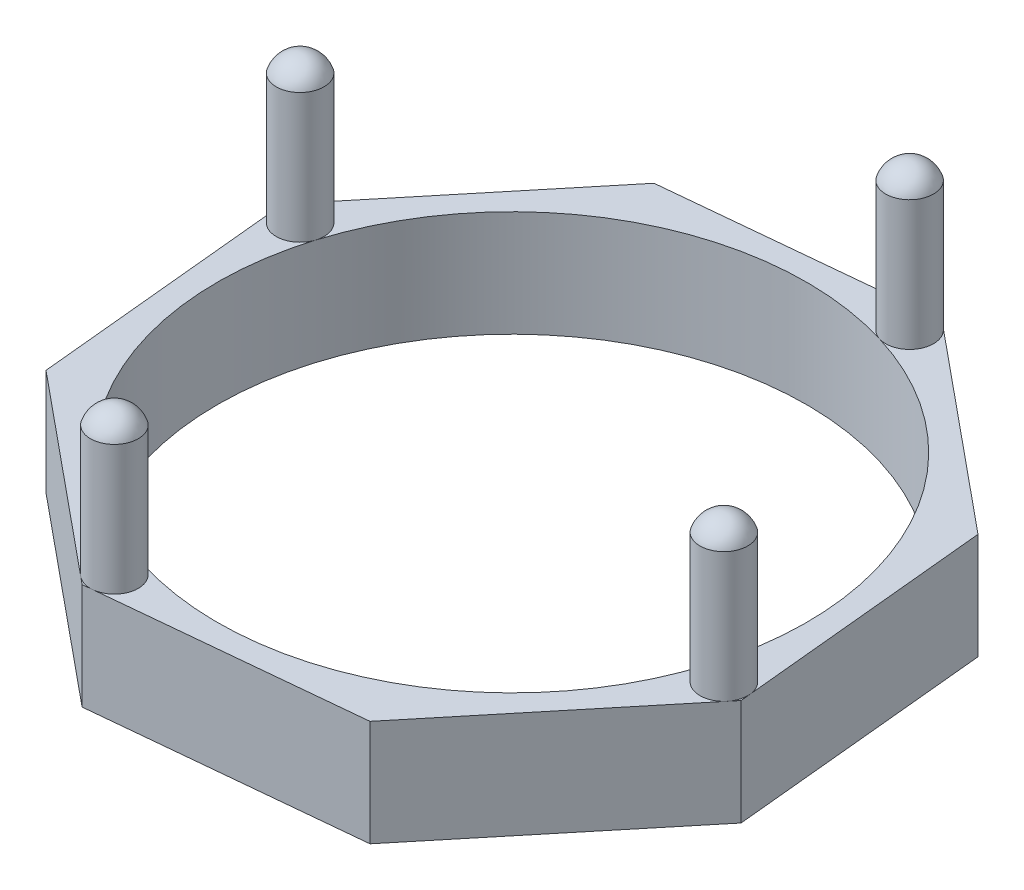
from build123d import *

# Parameters (mm, degrees)
SKETCH1_R           = 50
BOSS_EXTRUDE1_DEPTH = 18
SKETCH2_R           = 4.057438755
BOSS_EXTRUDE2_DEPTH = 22
DOME1_FACE_RADIUS   = 4.057438755
DOME1_HEIGHT        = 3
DOME2_FACE_RADIUS   = 4.057438755
DOME2_HEIGHT        = 3
DOME3_FACE_RADIUS   = 4.057438755
DOME3_HEIGHT        = 3
DOME4_FACE_RADIUS   = 4.057438755
DOME4_HEIGHT        = 3


with BuildPart() as part:
    # Sketch1 → Boss-Extrude1 (new body)
    with BuildSketch(Plane(origin=(0, 0, 0), x_dir=(1, 0, 0), z_dir=(0, 1, 0))):
        Polygon((-27.487628691, 51.582330048), (-55.910904013, 17.03752672), (-51.582330048, -27.487628691), (-17.03752672, -55.910904013), (27.487628691, -51.582330048), (55.910904013, -17.03752672), (51.582330048, 27.487628691), (17.03752672, 55.910904013), align=None)
        Circle(SKETCH1_R, mode=Mode.SUBTRACT)
    extrude(amount=BOSS_EXTRUDE1_DEPTH)

    # Sketch2 → Boss-Extrude2 (add)
    with BuildSketch(Plane(origin=(0, 18, 0), x_dir=(1, 0, 0), z_dir=(0, 1, 0))):
        with Locations((-51.709884221, 15.757365217)):
            Circle(SKETCH2_R)
        with Locations((15.757365217, 51.709884221)):
            Circle(SKETCH2_R)
        with Locations((51.709884221, -15.757365217)):
            Circle(SKETCH2_R)
        with Locations((-15.757365217, -51.709884221)):
            Circle(SKETCH2_R)
    extrude(amount=BOSS_EXTRUDE2_DEPTH)

    # Dome1: a dome of height H over a round flat face of radius A is a cap of a sphere of radius (A * A + H * H) / (2 * H)
    dome1_r = (DOME1_FACE_RADIUS * DOME1_FACE_RADIUS + DOME1_HEIGHT * DOME1_HEIGHT) / (2 * DOME1_HEIGHT)
    dome1_base = Plane((-51.709884221, 40, -15.757365217), z_dir=(0, 1, 0))
    with Locations(dome1_base.offset(DOME1_HEIGHT - dome1_r)):
        dome1_ball = Sphere(dome1_r, mode=Mode.PRIVATE)
    add(split(dome1_ball, bisect_by=dome1_base, keep=Keep.TOP, mode=Mode.PRIVATE))

    # Dome2: a dome of height H over a round flat face of radius A is a cap of a sphere of radius (A * A + H * H) / (2 * H)
    dome2_r = (DOME2_FACE_RADIUS * DOME2_FACE_RADIUS + DOME2_HEIGHT * DOME2_HEIGHT) / (2 * DOME2_HEIGHT)
    dome2_base = Plane((15.757365217, 40, -51.709884221), z_dir=(0, 1, 0))
    with Locations(dome2_base.offset(DOME2_HEIGHT - dome2_r)):
        dome2_ball = Sphere(dome2_r, mode=Mode.PRIVATE)
    add(split(dome2_ball, bisect_by=dome2_base, keep=Keep.TOP, mode=Mode.PRIVATE))

    # Dome3: a dome of height H over a round flat face of radius A is a cap of a sphere of radius (A * A + H * H) / (2 * H)
    dome3_r = (DOME3_FACE_RADIUS * DOME3_FACE_RADIUS + DOME3_HEIGHT * DOME3_HEIGHT) / (2 * DOME3_HEIGHT)
    dome3_base = Plane((51.709884221, 40, 15.757365217), z_dir=(0, 1, 0))
    with Locations(dome3_base.offset(DOME3_HEIGHT - dome3_r)):
        dome3_ball = Sphere(dome3_r, mode=Mode.PRIVATE)
    add(split(dome3_ball, bisect_by=dome3_base, keep=Keep.TOP, mode=Mode.PRIVATE))

    # Dome4: a dome of height H over a round flat face of radius A is a cap of a sphere of radius (A * A + H * H) / (2 * H)
    dome4_r = (DOME4_FACE_RADIUS * DOME4_FACE_RADIUS + DOME4_HEIGHT * DOME4_HEIGHT) / (2 * DOME4_HEIGHT)
    dome4_base = Plane((-15.757365217, 40, 51.709884221), z_dir=(0, 1, 0))
    with Locations(dome4_base.offset(DOME4_HEIGHT - dome4_r)):
        dome4_ball = Sphere(dome4_r, mode=Mode.PRIVATE)
    add(split(dome4_ball, bisect_by=dome4_base, keep=Keep.TOP, mode=Mode.PRIVATE))


solid = part.part
